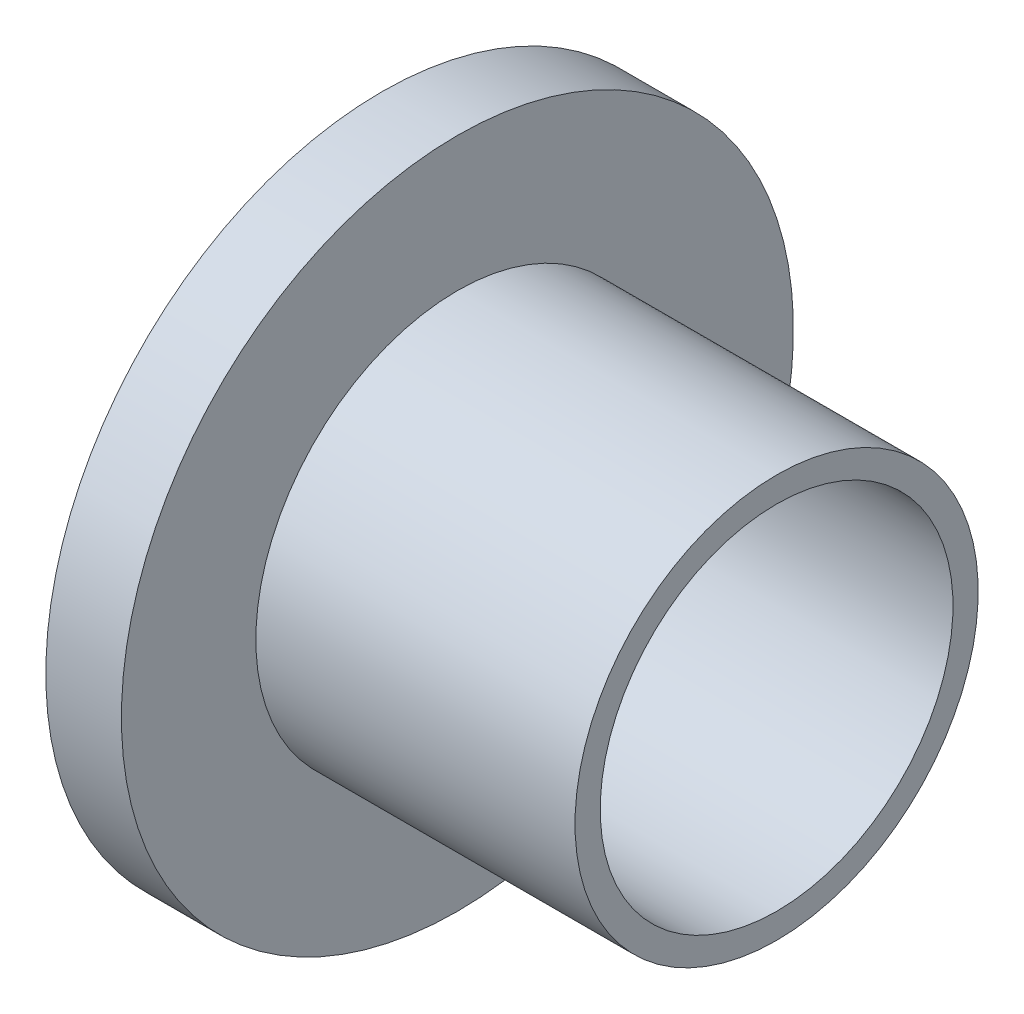
from build123d import *


with BuildPart() as part:
    # Sketch2 → Revolve1 (revolve)
    with BuildSketch(Plane.XY):
        Polygon((0, 90.08461108), (6.000975173, 90.08461108), (6.000975173, 74.083147589), (46.998004551, 74.083147589), (46.998004551, 77.083147589), (9.000975173, 77.083147589), (9.000975173, 93.08461108), (0, 93.08461108), align=None)
    revolve(axis=Axis((0, 53.084679681, 0), (1, 0, 0)))


solid = part.part
